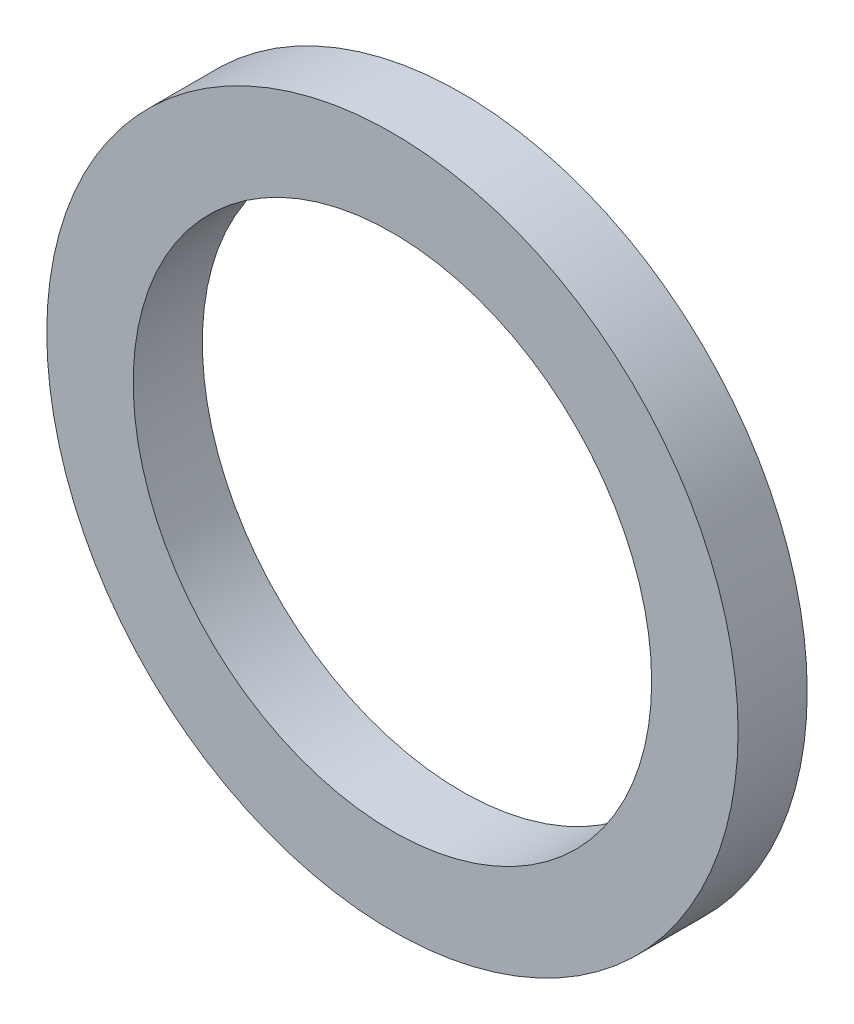
from build123d import *

# Parameters (mm, degrees)
SKETCH1_R          = 6.35
SKETCH1_R_2        = 4.7625
BASE_EXTRUDE_DEPTH = 1.27


with BuildPart() as part:
    # Sketch1 → Base-Extrude (new body)
    with BuildSketch(Plane.XY):
        with Locations((0, 21.461256505)):
            Circle(SKETCH1_R)
        with Locations((0, 21.461256505)):
            Circle(SKETCH1_R_2, mode=Mode.SUBTRACT)
    extrude(amount=BASE_EXTRUDE_DEPTH)


solid = part.part
